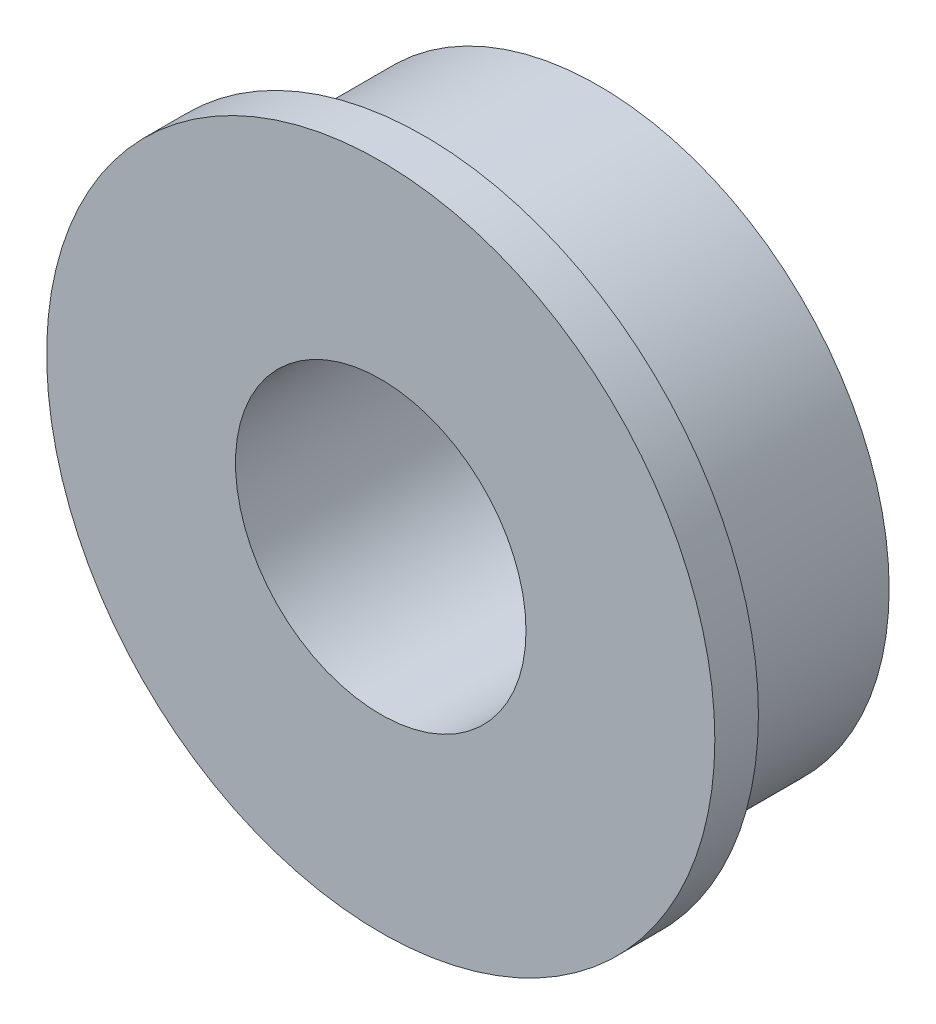
from build123d import *

# Parameters (mm, degrees)
SKETCH1_R           = 4
SKETCH1_R_2         = 2
BOSS_EXTRUDE1_DEPTH = 3
SKETCH2_R           = 4
SKETCH2_R_2         = 2
SKETCH2_R_3         = 4.6
BOSS_EXTRUDE2_DEPTH = 0.6


with BuildPart() as part:
    # Sketch1 → Boss-Extrude1 (new body)
    with BuildSketch(Plane.XY):
        Circle(SKETCH1_R)
        Circle(SKETCH1_R_2, mode=Mode.SUBTRACT)
    extrude(amount=-BOSS_EXTRUDE1_DEPTH)

    # Sketch2 → Boss-Extrude2 (add)
    with BuildSketch(Plane.XY):
        Circle(SKETCH2_R)
        Circle(SKETCH2_R_2, mode=Mode.SUBTRACT)
        Circle(SKETCH2_R_3)
        Circle(SKETCH2_R, mode=Mode.SUBTRACT)
    extrude(amount=-BOSS_EXTRUDE2_DEPTH)


solid = part.part
